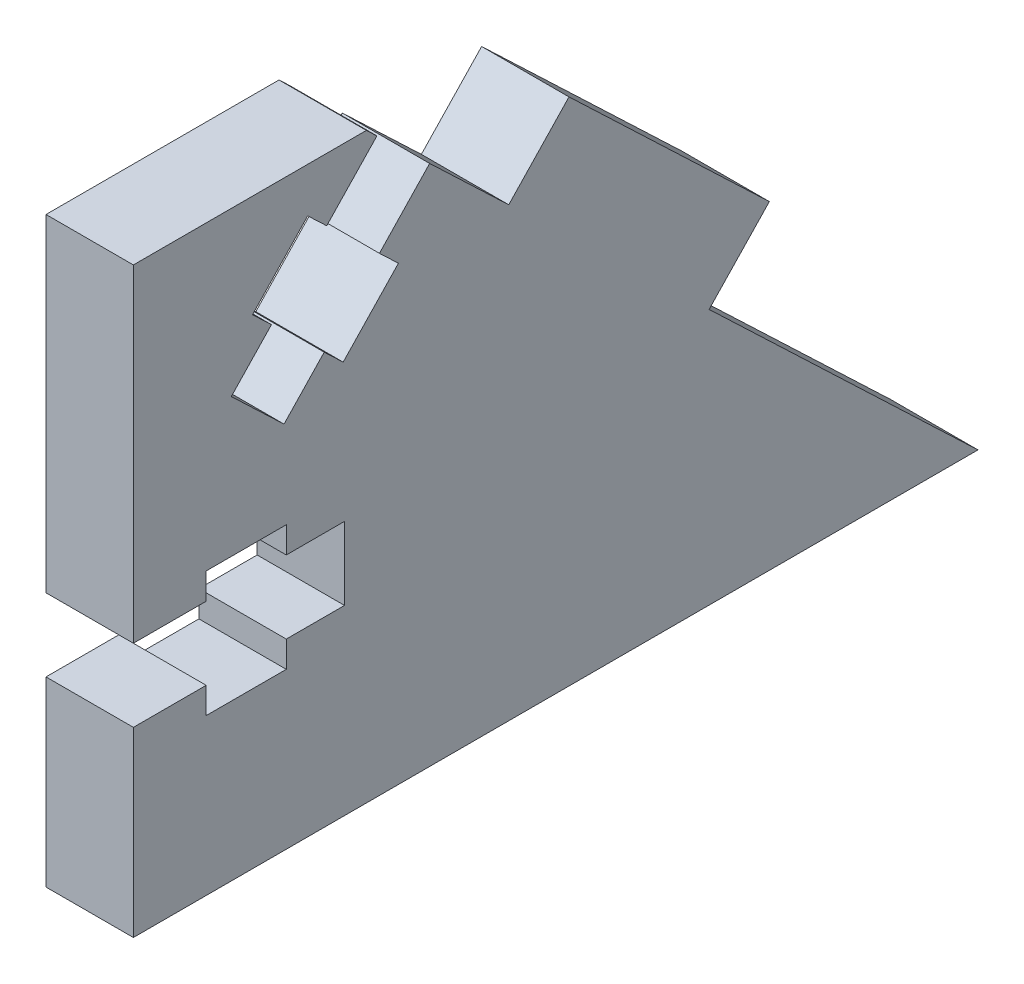
from build123d import *

# Parameters (mm, degrees)
BOSS_EXTRU_1_DEPTH      = 6
ENL_V_MAT_EXTRU_1_DEPTH = 6


with BuildPart() as part:
    # Esquisse1 → Boss.-Extru.1 (new body)
    with BuildSketch(Plane(origin=(0, 0, 0), x_dir=(0, 0, -1), z_dir=(1, 0, 0))):
        Polygon((0, 0), (0, 40), (16, 40), (25.775862069, 30.689655172), (29.913793103, 35.034482759), (43.672413793, 21.931034483), (39.534482759, 17.586206897), (58, 0), align=None)
    extrude(amount=BOSS_EXTRU_1_DEPTH)

    # Esquisse2 → Enlèv. mat.-Extru.1 (cut)
    with BuildSketch(Plane(origin=(6, 0, 0), x_dir=(0, 0, -1), z_dir=(1, 0, 0))):
        Polygon((0, 17.5), (0, 12.5), (5, 12.5), (5, 10.7), (10.5, 10.7), (10.5, 12.5), (14.5, 12.5), (14.5, 17.5), (10.5, 17.5), (10.5, 19.3), (5, 19.3), (5, 17.5), align=None)
        Polygon((20.344827586, 35.862068966), (16.724137931, 39.310344828), (13.275862069, 35.689655172), (11.972413793, 36.931034483), (8.179310345, 32.948275862), (9.482758621, 31.706896552), (6.724137931, 28.810344828), (10.344827586, 25.362068966), (13.103448276, 28.25862069), (14.406896552, 27.017241379), (18.2, 31), (16.896551724, 32.24137931), align=None)
    extrude(amount=-ENL_V_MAT_EXTRU_1_DEPTH, mode=Mode.SUBTRACT)


solid = part.part
